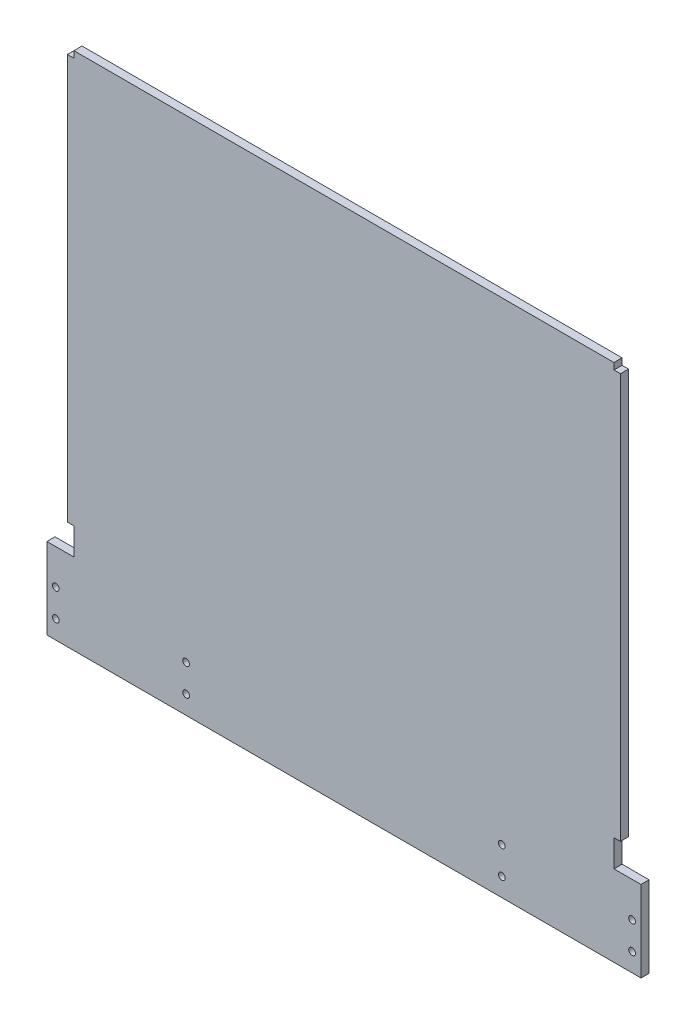
from build123d import *

# Parameters (mm, degrees)
BOSS_EXTRU_1_DEPTH      = 3
ESQUISSE2_R             = 1.25
ENL_V_MAT_EXTRU_1_DEPTH = 10


with BuildPart() as part:
    # Esquisse1 → Boss.-Extru.1 (new body)
    with BuildSketch(Plane.XY):
        Polygon((-56.390469464, -21.033092325), (-56.390469464, -51.033092325), (163.609530536, -51.033092325), (163.609530536, -21.033092325), (153.609530536, -21.033092325), (153.609530536, -11.033092325), (156.009530536, -11.033092325), (156.009530536, 138.966907675), (153.609530536, 138.966907675), (153.609530536, 141.366907675), (-46.390469464, 141.366907675), (-46.390469464, 138.966907675), (-48.790469464, 138.966907675), (-48.790469464, -11.033092325), (-46.390469464, -11.033092325), (-46.390469464, -21.033092325), align=None)
    extrude(amount=BOSS_EXTRU_1_DEPTH)

    # Esquisse2 → Enlèv. mat.-Extru.1 (cut)
    with BuildSketch(Plane.XY.offset(3)):
        with Locations((160.319530536, -34.033092325)):
            Circle(ESQUISSE2_R)
        with Locations((112.059530536, -34.033092325)):
            Circle(ESQUISSE2_R)
        with Locations((160.319530536, -44.193092325)):
            Circle(ESQUISSE2_R)
        with Locations((112.059530536, -44.193092325)):
            Circle(ESQUISSE2_R)
        with Locations((-4.840469464, -44.193092325)):
            Circle(ESQUISSE2_R)
        with Locations((-53.100469464, -44.193092325)):
            Circle(ESQUISSE2_R)
        with Locations((-4.840469464, -34.033092325)):
            Circle(ESQUISSE2_R)
        with Locations((-53.100469464, -34.033092325)):
            Circle(ESQUISSE2_R)
    extrude(amount=-ENL_V_MAT_EXTRU_1_DEPTH, mode=Mode.SUBTRACT)


solid = part.part
